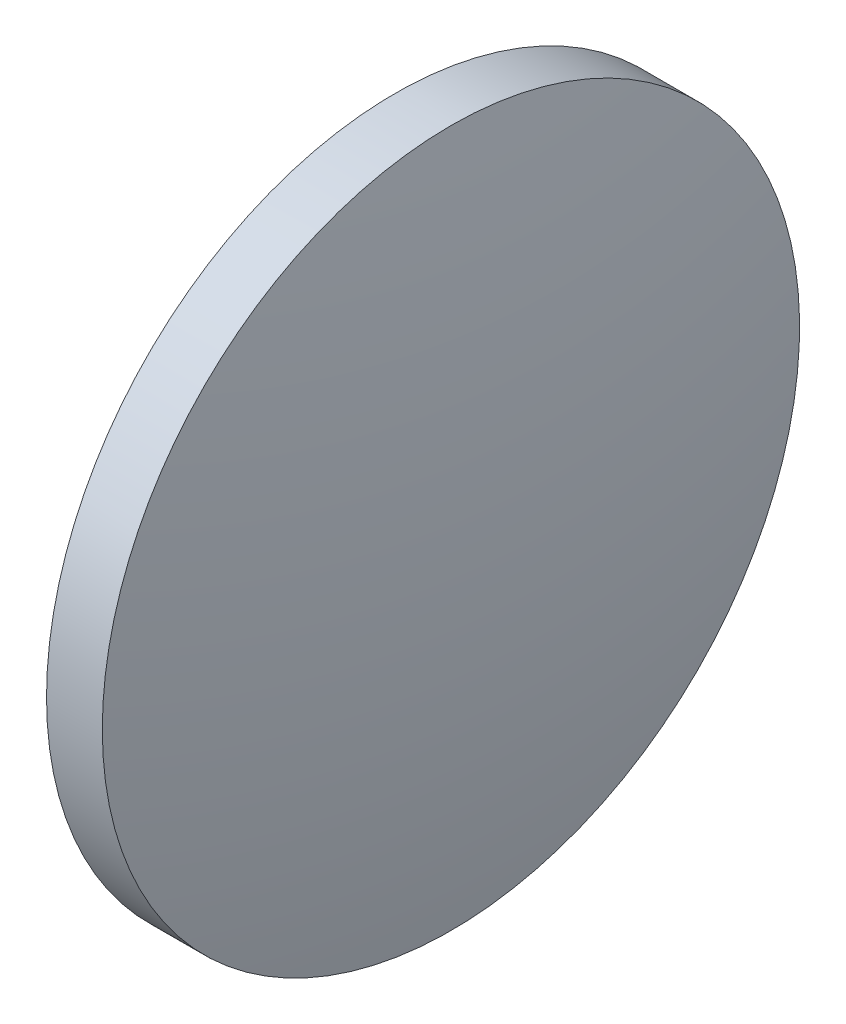
from build123d import *


with BuildPart() as part:
    # 草图2 → 旋转2 (revolve)
    with BuildSketch(Plane.XY):
        with BuildLine():
            Line((661.694457284, 112.677785052), (661.694457284, 125.177785052))
            Line((661.694457284, 125.177785052), (663.694457284, 125.177785052))
            ThreePointArc((663.694457284, 125.177785052), (664.608734384, 118.957482497), (664.914457284, 112.677785052))
            Line((664.914457284, 112.677785052), (661.694457284, 112.677785052))
        make_face()
    revolve(axis=Axis((659.328841381, 112.677785052, 0), (1, 0, 0)))


solid = part.part
